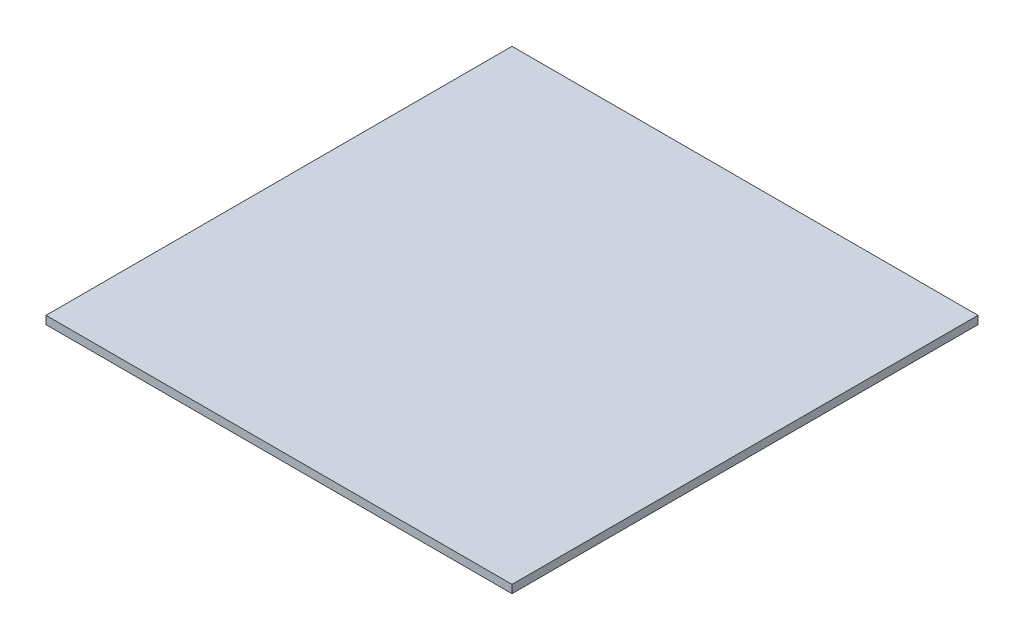
from build123d import *

# Parameters (mm, degrees)
SKETCH_1_W      = 103.6
SKETCH_1_H      = 103.6
EXTRUDE_1_DEPTH = 1.8


with BuildPart() as part:
    # 草图1 → 凸台-拉伸1 (new body)
    with BuildSketch(Plane(origin=(0, 0, 0), x_dir=(1, 0, 0), z_dir=(0, 1, 0))):
        with Locations((51.8, 51.8)):
            Rectangle(SKETCH_1_W, SKETCH_1_H)
    extrude(amount=EXTRUDE_1_DEPTH)


solid = part.part
